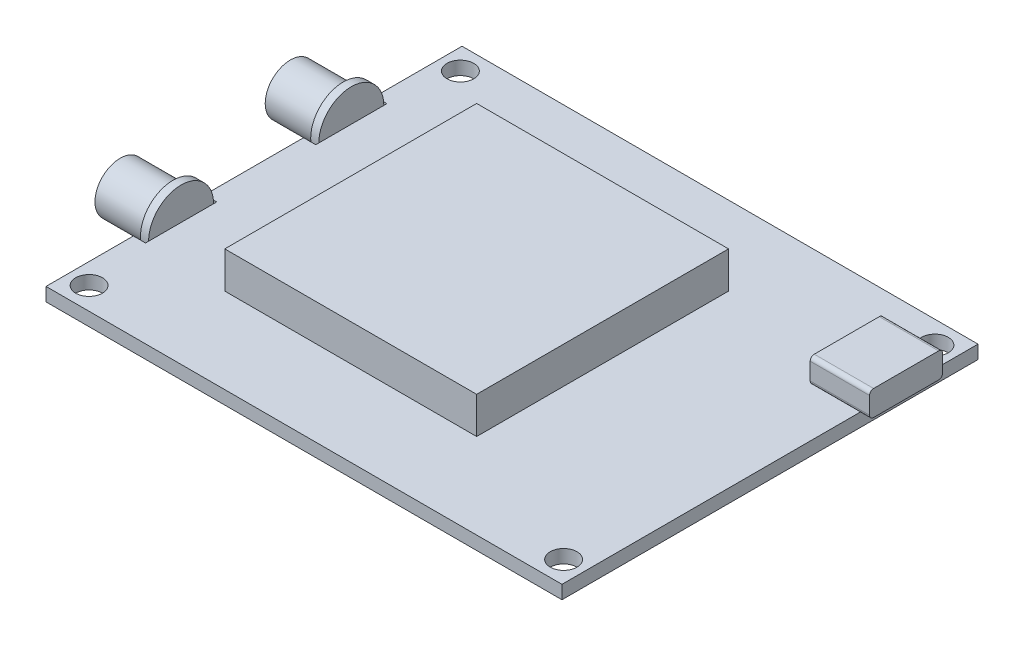
from build123d import *

# Parameters (mm, degrees)
SKETCH1_W               = 63.5
SKETCH1_H               = 51.2
BOSS_EXTRUDE1_DEPTH     = 1.65
SKETCH2_W               = 31
SKETCH2_H               = 31
BOSS_EXTRUDE2_DEPTH     = 4.5
SKETCH3_W               = 8.75
SKETCH3_H               = 1.65
CUT_EXTRUDE1_DEPTH      = 1.5
SKETCH4_R               = 4
BOSS_EXTRUDE3_DEPTH     = 1
SKETCH5_R               = 3.1
BOSS_EXTRUDE4_DEPTH     = 6.5
SKETCH6_R               = 1.65
CUT_EXTRUDE2_DEPTH      = 5.5
CUT_EXTRUDE2_DEPTH_BACK = 1.65
BOSS_EXTRUDE5_DEPTH     = 7.3


with BuildPart() as part:
    # Sketch1 → Boss-Extrude1 (new body)
    with BuildSketch(Plane(origin=(0, 0, 0), x_dir=(1, 0, 0), z_dir=(0, 1, 0))):
        with Locations((-1.867647059, -5.657328016)):
            Rectangle(SKETCH1_W, SKETCH1_H)
    extrude(amount=BOSS_EXTRUDE1_DEPTH)

    # Sketch2 → Boss-Extrude2 (add)
    with BuildSketch(Plane(origin=(0, 1.65, 0), x_dir=(1, 0, 0), z_dir=(0, 1, 0))):
        with Locations((-6.617647059, -5.257328016)):
            Rectangle(SKETCH2_W, SKETCH2_H)
    extrude(amount=BOSS_EXTRUDE2_DEPTH)

    # Sketch3 → Cut-Extrude1 (cut)
    with BuildSketch(Plane.ZY.offset(33.617647059)):
        with Locations((-4.817671984, 0.825)):
            Rectangle(SKETCH3_W, SKETCH3_H)
        with Locations((16.132328016, 0.825)):
            Rectangle(SKETCH3_W, SKETCH3_H)
    extrude(amount=-CUT_EXTRUDE1_DEPTH, mode=Mode.SUBTRACT)

    # Sketch4 → Boss-Extrude3 (add)
    with BuildSketch(Plane.ZY.offset(32.117647059)):
        with Locations((-4.817671984, 1.65)):
            Circle(SKETCH4_R)
    boss_extrude3 = extrude(amount=BOSS_EXTRUDE3_DEPTH)

    # Sketch5 → Boss-Extrude4 (add)
    with BuildSketch(Plane.ZY.offset(33.117647059)):
        with Locations((-4.817671984, 1.65)):
            Circle(SKETCH5_R)
    boss_extrude4 = extrude(amount=BOSS_EXTRUDE4_DEPTH)

    # Mirror1: Boss-Extrude3, Boss-Extrude4 across plane
    add(boss_extrude3.mirror(Plane(origin=(0, 0, 5.657328016), x_dir=(1, 0, 0), z_dir=(0, 0, -1))))
    add(boss_extrude4.mirror(Plane(origin=(0, 0, 5.657328016), x_dir=(1, 0, 0), z_dir=(0, 0, -1))))

    # Sketch6 → Cut-Extrude2 (cut, two sides)
    with BuildSketch(Plane(origin=(0, 1.65, 0), x_dir=(1, 0, 0), z_dir=(0, 1, 0))) as cut_extrude2_sk:
        with Locations((-31.067647059, 17.192671984)):
            Circle(SKETCH6_R)
        with Locations((-31.067647059, -28.507328016)):
            Circle(SKETCH6_R)
        with Locations((27.332352941, -28.507328016)):
            Circle(SKETCH6_R)
        with Locations((27.332352941, 17.192671984)):
            Circle(SKETCH6_R)
    extrude(amount=CUT_EXTRUDE2_DEPTH, mode=Mode.SUBTRACT)
    extrude(cut_extrude2_sk.sketch, amount=-CUT_EXTRUDE2_DEPTH_BACK, mode=Mode.SUBTRACT)

    # Sketch7 → Boss-Extrude5 (add)
    with BuildSketch(Plane(origin=(23.982352941, 0, 0), x_dir=(0, 0, -1), z_dir=(1, 0, 0))):
        with BuildLine():
            Line((13.692671984, 1.65), (5.692671984, 1.65))
            ThreePointArc((5.692671984, 1.65), (5.339118593, 1.796446609), (5.192671984, 2.15))
            Line((5.192671984, 2.15), (5.192671984, 4.25))
            ThreePointArc((5.192671984, 4.25), (5.339118593, 4.603553391), (5.692671984, 4.75))
            Line((5.692671984, 4.75), (13.692671984, 4.75))
            ThreePointArc((13.692671984, 4.75), (14.046225375, 4.603553391), (14.192671984, 4.25))
            Line((14.192671984, 4.25), (14.192671984, 2.15))
            ThreePointArc((14.192671984, 2.15), (14.046225375, 1.796446609), (13.692671984, 1.65))
        make_face()
    extrude(amount=BOSS_EXTRUDE5_DEPTH)


solid = part.part
